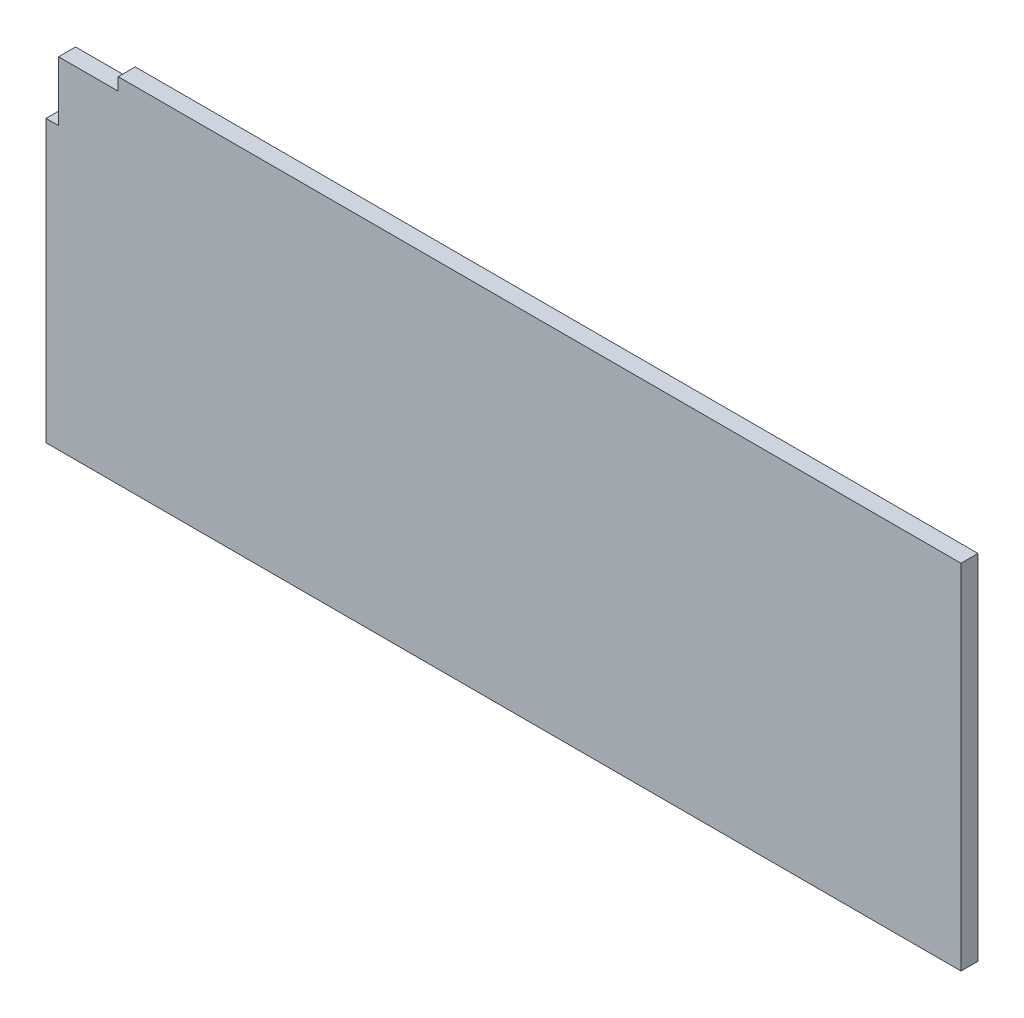
from build123d import *

# Parameters (mm, degrees)
BOSS_EXTRUDE1_DEPTH = 6.35


with BuildPart() as part:
    # Sketch1 → Boss-Extrude1 (new body)
    with BuildSketch(Plane.XY):
        Polygon((27, 132), (27, 127.3), (4.7, 127.3), (4.7, 105), (0, 105), (0, 0), (342, 0), (342, 132), align=None)
    extrude(amount=BOSS_EXTRUDE1_DEPTH)


solid = part.part
